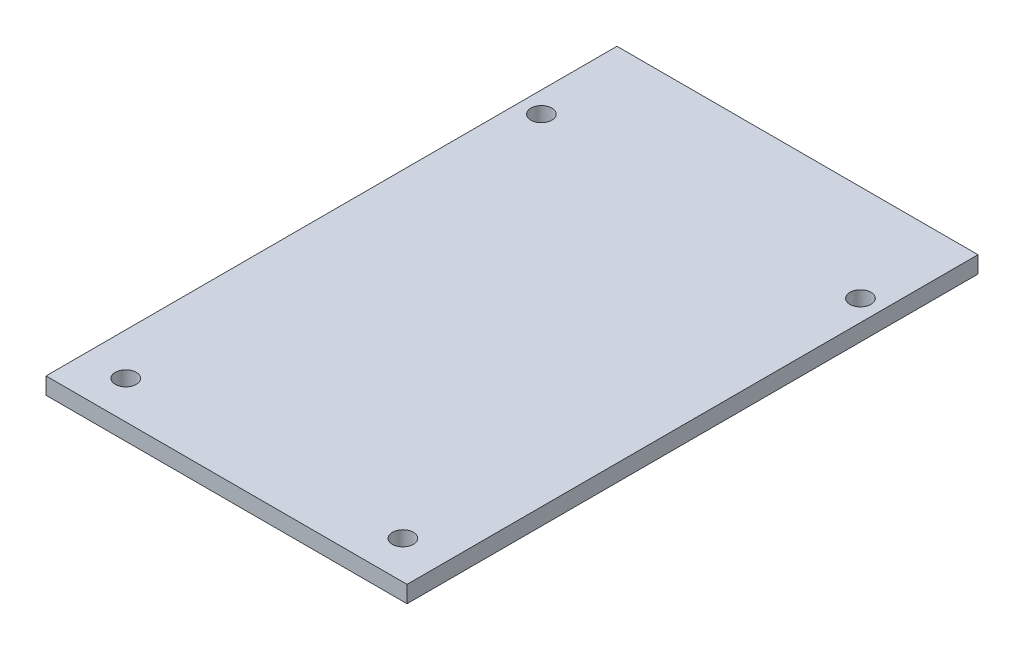
from build123d import *

# Parameters (mm, degrees)
SKETCH1_W           = 54.61
SKETCH1_H           = 86.36
BOSS_EXTRUDE1_DEPTH = 2.54
SKETCH2_R           = 1.5875
CUT_EXTRUDE1_DEPTH  = 3.54


with BuildPart() as part:
    # Sketch1 → Boss-Extrude1 (new body)
    with BuildSketch(Plane(origin=(0, 0, 0), x_dir=(1, 0, 0), z_dir=(0, 1, 0))):
        with Locations((27.305, 43.18)):
            Rectangle(SKETCH1_W, SKETCH1_H)
    extrude(amount=BOSS_EXTRUDE1_DEPTH)

    # Sketch2 → Cut-Extrude1 (cut, through all)
    with BuildSketch(Plane(origin=(0, 2.54, 0), x_dir=(1, 0, 0), z_dir=(0, 1, 0))):
        with Locations((3.175, 71.755)):
            Circle(SKETCH2_R)
        with Locations((51.435, 71.755)):
            Circle(SKETCH2_R)
        with Locations((6.35, 5.715)):
            Circle(SKETCH2_R)
        with Locations((48.26, 5.715)):
            Circle(SKETCH2_R)
    extrude(amount=-CUT_EXTRUDE1_DEPTH, mode=Mode.SUBTRACT)


solid = part.part
